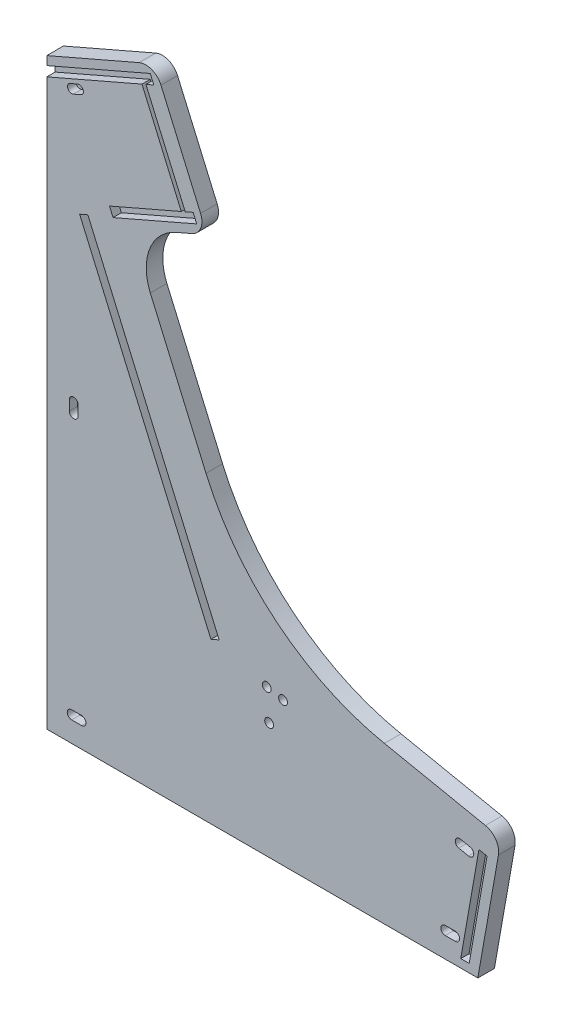
from build123d import *

# Parameters (mm, degrees)
SALIENTE_EXTRUIR1_DEPTH = 10
REDONDEO1_R             = 30
REDONDEO2_R             = 150
REDONDEO3_R             = 10
CORTAR_EXTRUIR1_DEPTH   = 5
CROQUIS4_R              = 2.65
CORTAR_EXTRUIR3_DEPTH   = 5


with BuildPart() as part:
    # Croquis1 → Saliente-Extruir1 (new body)
    with BuildSketch(Plane.XY):
        Polygon((0, 0), (260, 0), (274.106158457, 80), (127.13677389, 110), (50.509014114, 286.543118386), (96.75188515, 306.61463205), (64.899290737, 380), (0, 351.830749872), align=None)
    extrude(amount=SALIENTE_EXTRUIR1_DEPTH)

    # Redondeo1
    redondeo1_edges = [part.edges().sort_by_distance(p)[0] for p in [
        (50.509014114, 286.543118386, 5),
    ]]
    fillet(redondeo1_edges, radius=REDONDEO1_R)

    # Redondeo2
    redondeo2_edges = [part.edges().sort_by_distance(p)[0] for p in [
        (127.13677389, 110, 5),
    ]]
    fillet(redondeo2_edges, radius=REDONDEO2_R)

    # Redondeo3
    redondeo3_edges = [part.edges().sort_by_distance(p)[0] for p in [
        (64.899290737, 380, 5),
        (96.75188515, 306.61463205, 5),
        (274.106158457, 80, 5),
    ]]
    fillet(redondeo3_edges, radius=REDONDEO3_R)

    # Croquis2 → Cortar-Extruir1 (cut)
    with BuildSketch(Plane.XY.offset(10)):
        Polygon((39.986675692, 287.208594669), (90.439116158, 309.107253328), (88.289066035, 314.060765665), (83.517508369, 311.989692162), (59.787325531, 366.661791285), (64.558883197, 368.732864788), (62.408833074, 373.686377124), (0, 346.598099131), (0, 340.711367047), (57.402301073, 365.626581966), (81.13248391, 310.954482844), (37.836625569, 292.162107006), align=None)
    extrude(amount=-CORTAR_EXTRUIR1_DEPTH, mode=Mode.SUBTRACT)

    # Croquis4 → Cortar-Extruir3 (cut)
    with BuildSketch(Plane.XY.offset(10)):
        with Locations((132.709363959, 88.450085292)):
            Circle(CROQUIS4_R)
        with Locations((142.50732293, 86.450085292)):
            Circle(CROQUIS4_R)
        with Locations((134.109252611, 70.308111078)):
            Circle(CROQUIS4_R)
        Polygon((254.785909436, 5), (265.569150028, 66.433298656), (260.668303978, 67.433679667), (249.709468889, 5), align=None)
        with BuildLine():
            Line((240.334745072, 17.65), (246.334745072, 17.65))
            ThreePointArc((246.334745072, 17.65), (248.984745072, 15), (246.334745072, 12.35))
            Line((246.334745072, 12.35), (240.334745072, 12.35))
            ThreePointArc((240.334745072, 12.35), (237.684745072, 15), (240.334745072, 17.65))
        make_face()
        with BuildLine():
            Line((249.552515929, 67.294739764), (255.431207696, 66.094330202))
            ThreePointArc((255.431207696, 66.094330202), (257.497449003, 62.967727115), (254.370845916, 60.901485808))
            Line((254.370845916, 60.901485808), (248.49215415, 62.10189537))
            ThreePointArc((248.49215415, 62.10189537), (246.425912843, 65.228498457), (249.552515929, 67.294739764))
        make_face()
        with BuildLine():
            Line((15, 17.65), (21, 17.65))
            ThreePointArc((21, 17.65), (23.65, 15), (21, 12.35))
            Line((21, 12.35), (15, 12.35))
            ThreePointArc((15, 12.35), (12.35, 15), (15, 17.65))
        make_face()
        Polygon((99.011814836, 96.436284415), (19.818301977, 278.890655481), (24.771814314, 281.040705604), (103.965327172, 98.586334538), align=None)
        with BuildLine():
            Line((13.6, 178.915374936), (13.6, 172.915374936))
            ThreePointArc((13.6, 172.915374936), (16.25, 170.265374936), (18.9, 172.915374936))
            Line((18.9, 172.915374936), (18.9, 178.915374936))
            ThreePointArc((18.9, 178.915374936), (16.25, 181.565374936), (13.6, 178.915374936))
        make_face()
        with BuildLine():
            Line((14.004606425, 344.282692717), (18.591191921, 346.273479867))
            ThreePointArc((18.591191921, 346.273479867), (21.879878245, 344.975580694), (20.581979072, 341.686894371))
            Line((20.581979072, 341.686894371), (15.995393575, 339.69610722))
            ThreePointArc((15.995393575, 339.69610722), (12.706707252, 340.994006393), (14.004606425, 344.282692717))
        make_face()
    extrude(amount=-CORTAR_EXTRUIR3_DEPTH, mode=Mode.SUBTRACT)


solid = part.part
